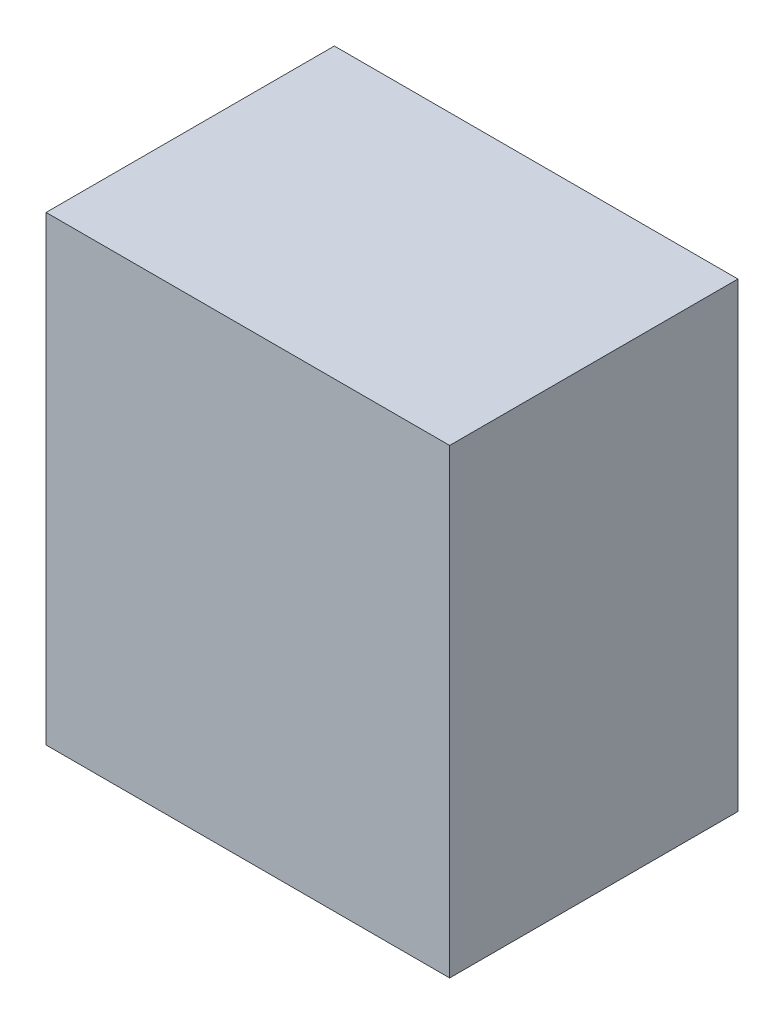
from build123d import *

# Parameters (mm, degrees)
SCHIZZO1_W                   = 35
SCHIZZO1_H                   = 40
ESTRUSIONE_ESTRUSIONE1_DEPTH = 25


with BuildPart() as part:
    # Schizzo1 → Estrusione-Estrusione1 (new body)
    with BuildSketch(Plane.XY):
        with Locations((17.5, 20)):
            Rectangle(SCHIZZO1_W, SCHIZZO1_H)
    extrude(amount=ESTRUSIONE_ESTRUSIONE1_DEPTH)


solid = part.part
